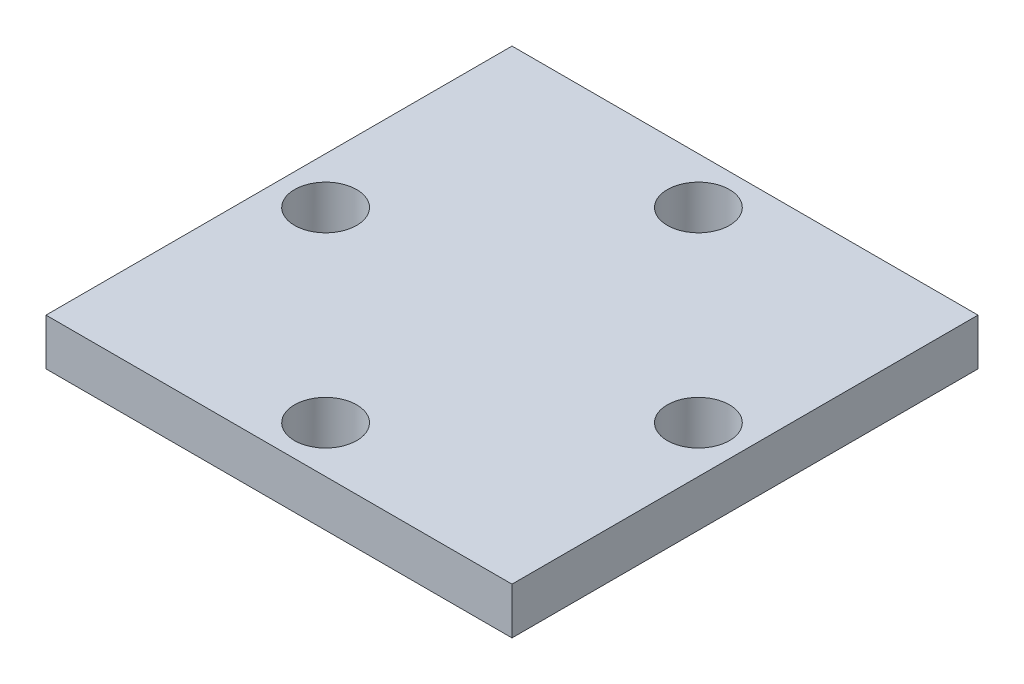
from build123d import *

# Parameters (mm, degrees)
SKETCH_1_W          = 30
SKETCH_1_H          = 30
EXTRUDE_1_DEPTH     = 3
SKETCH_2_R          = 2
CUT_EXTRUDE_1_DEPTH = 5


with BuildPart() as part:
    # 草圖1 → 填料-伸長1 (new body)
    with BuildSketch(Plane(origin=(0, 0, 0), x_dir=(1, 0, 0), z_dir=(0, 1, 0))):
        Rectangle(SKETCH_1_W, SKETCH_1_H)
    extrude(amount=EXTRUDE_1_DEPTH)

    # 草圖2 → 除料-伸長1 (cut)
    with BuildSketch(Plane(origin=(0, 3, 0), x_dir=(1, 0, 0), z_dir=(0, 1, 0))):
        with Locations((-12, 0)):
            Circle(SKETCH_2_R)
        with Locations((12, 0)):
            Circle(SKETCH_2_R)
        with Locations((0, 12)):
            Circle(SKETCH_2_R)
        with Locations((0, -12)):
            Circle(SKETCH_2_R)
    extrude(amount=-CUT_EXTRUDE_1_DEPTH, mode=Mode.SUBTRACT)


solid = part.part
